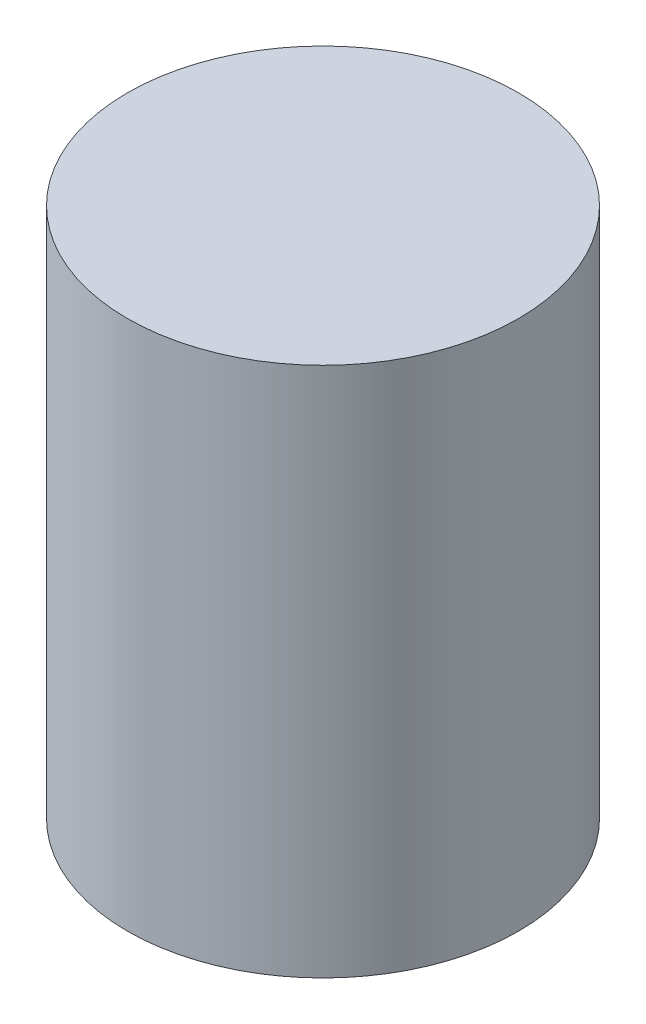
from build123d import *

# Parameters (mm, degrees)
SKETCH1_R           = 11
BOSS_EXTRUDE2_DEPTH = 29.85


with BuildPart() as part:
    # Sketch1 → Boss-Extrude2 (new body)
    with BuildSketch(Plane(origin=(0, 0, 0), x_dir=(1, 0, 0), z_dir=(0, 1, 0))):
        with Locations((-22.770576779, 24.323116105)):
            Circle(SKETCH1_R)
    extrude(amount=BOSS_EXTRUDE2_DEPTH)


solid = part.part
